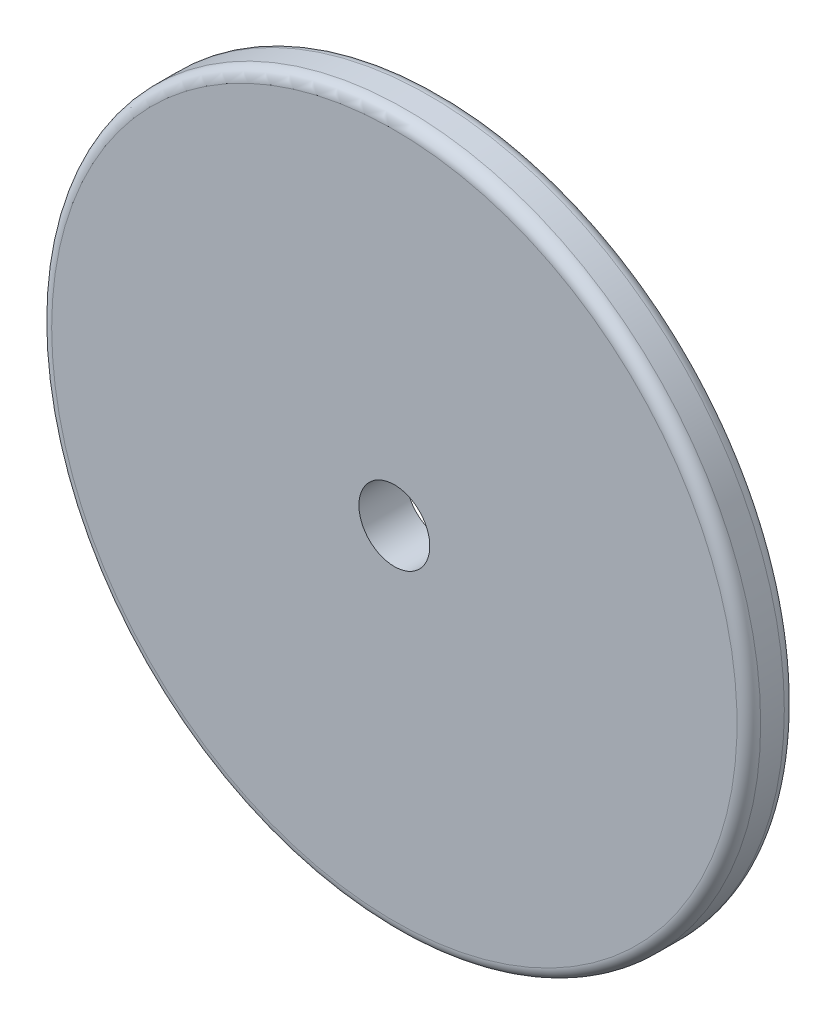
from build123d import *

# Parameters (mm, degrees)
SKETCH2_R           = 15
SKETCH2_R_2         = 1.5
BOSS_EXTRUDE1_DEPTH = 2
FILLET1_R           = 0.5
FILLET3_R           = 0.5


with BuildPart() as part:
    # Sketch2 → Boss-Extrude1 (new body)
    with BuildSketch(Plane(origin=(-0.007077674, -0.003066892, 41.897062416), x_dir=(0.837169553, 0.546943422, 0.00018146), z_dir=(0.00016893, 7.3201e-05, -0.999999983))):
        with Locations((-55.821998493, 127.304785363)):
            Circle(SKETCH2_R)
        with Locations((-55.821998493, 127.304785363)):
            Circle(SKETCH2_R_2, mode=Mode.SUBTRACT)
    extrude(amount=BOSS_EXTRUDE1_DEPTH)

    # Fillet1
    fillet1_edges = [part.edges().sort_by_distance(p)[0] for p in [
        (10.331416884, -145.31438544, 41.888172015),
    ]]
    fillet(fillet1_edges, radius=FILLET1_R)

    # Fillet3
    fillet3_edges = [part.edges().sort_by_distance(p)[0] for p in [
        (10.331754744, -145.314239039, 39.888172049),
    ]]
    fillet(fillet3_edges, radius=FILLET3_R)


solid = part.part
